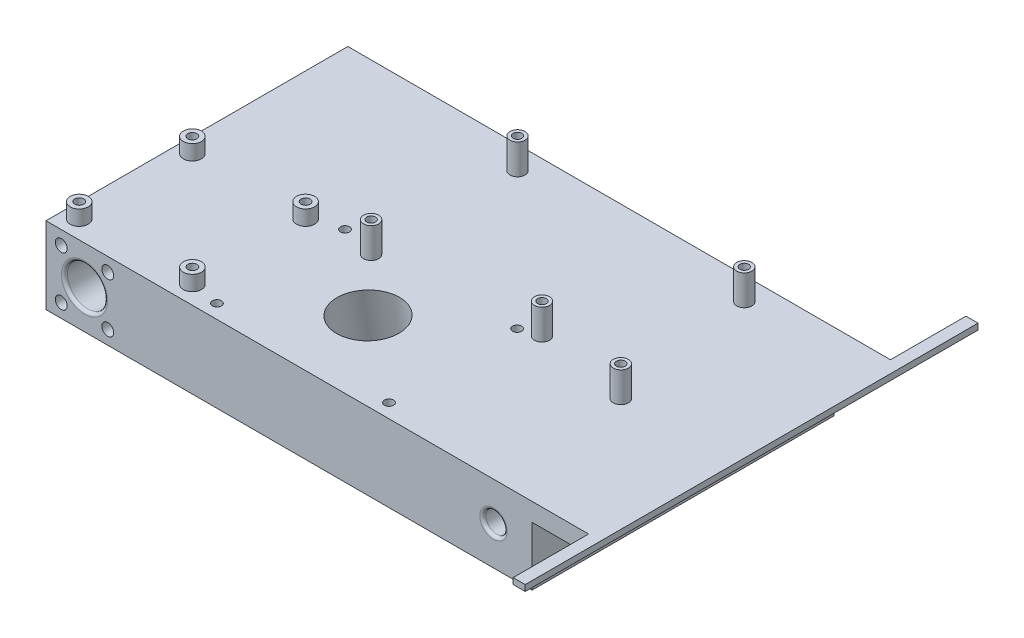
from build123d import *

# Parameters (mm, degrees)
SKETCH1_W                = 161
SKETCH1_H                = 100
BOSS_EXTRUDE1_DEPTH      = 12.75
BOSS_EXTRUDE1_DEPTH_BACK = 12.75
SKETCH2_R                = 6.63
SKETCH2_R_2              = 3.525
SKETCH2_R_3              = 1.975
CUT_EXTRUDE1_DEPTH       = 101
FILLET1_R                = 1
FILLET2_R                = 1
FILLET3_R                = 1
FILLET4_R                = 1
SKETCH3_R                = 2.5
BOSS_EXTRUDE2_DEPTH      = 10
SKETCH4_R                = 1.45
CUT_EXTRUDE2_DEPTH       = 5
SKETCH5_W                = 6
SKETCH5_H                = 13
CUT_EXTRUDE3_DEPTH       = 19.25
SKETCH6_R                = 10.25
CUT_EXTRUDE4_DEPTH       = 43.477415469
SKETCH8_R                = 1.5
CUT_EXTRUDE5_DEPTH       = 36.5
SKETCH11_R               = 3
BOSS_EXTRUDE4_DEPTH      = 5
SKETCH12_R               = 1.5
CUT_EXTRUDE7_DEPTH       = 5
SKETCH13_W               = 18.75
SKETCH13_H               = 6
BOSS_EXTRUDE5_DEPTH      = 100
SKETCH14_W               = 4
SKETCH14_H               = 2
BOSS_EXTRUDE6_DEPTH      = 25
BOSS_EXTRUDE6_DEPTH_BACK = 125


with BuildPart() as part:
    # Sketch1 → Boss-Extrude1 (new body, two sides)
    with BuildSketch(Plane(origin=(0, 0, 0), x_dir=(1, 0, 0), z_dir=(0, 1, 0))) as boss_extrude1_sk:
        Rectangle(SKETCH1_W, SKETCH1_H)
    extrude(amount=BOSS_EXTRUDE1_DEPTH)
    extrude(boss_extrude1_sk.sketch, amount=-BOSS_EXTRUDE1_DEPTH_BACK)

    # Sketch2 → Cut-Extrude1 (cut, through all)
    with BuildSketch(Plane.XY.offset(50)):
        with Locations((-67.75, 0)):
            Circle(SKETCH2_R)
        with Locations((67.75, 0)):
            Circle(SKETCH2_R_2)
        with Locations((-75.45, 8.2)):
            Circle(SKETCH2_R_3)
        with Locations((-75.45, -8.2)):
            Circle(SKETCH2_R_3)
        with Locations((-60.05, -8.2)):
            Circle(SKETCH2_R_3)
        with Locations((-60.05, 8.2)):
            Circle(SKETCH2_R_3)
    extrude(amount=-CUT_EXTRUDE1_DEPTH, mode=Mode.SUBTRACT)

    # Fillet1
    fillet1_edges = [part.edges().sort_by_distance(p)[0] for p in [
        (-74.38, 0, -50),
    ]]
    fillet(fillet1_edges, radius=FILLET1_R)

    # Fillet2
    fillet2_edges = [part.edges().sort_by_distance(p)[0] for p in [
        (-74.38, 0, 50),
    ]]
    fillet(fillet2_edges, radius=FILLET2_R)

    # Fillet3
    fillet3_edges = [part.edges().sort_by_distance(p)[0] for p in [
        (64.225, 0, 50),
    ]]
    fillet(fillet3_edges, radius=FILLET3_R)

    # Fillet4
    fillet4_edges = [part.edges().sort_by_distance(p)[0] for p in [
        (64.225, 0, -50),
    ]]
    fillet(fillet4_edges, radius=FILLET4_R)

    # Sketch3 → Boss-Extrude2 (add)
    with BuildSketch(Plane(origin=(0, 12.75, 0), x_dir=(1, 0, 0), z_dir=(0, 1, 0))):
        with Locations((-16.76, 42.46)):
            Circle(SKETCH3_R)
        with Locations((58.37, 42.46)):
            Circle(SKETCH3_R)
        with Locations((-17, -5.8)):
            Circle(SKETCH3_R)
        with Locations((34.7, -0.9)):
            Circle(SKETCH3_R)
        with Locations((65.72, -5.8)):
            Circle(SKETCH3_R)
    extrude(amount=BOSS_EXTRUDE2_DEPTH)

    # Sketch4 → Cut-Extrude2 (cut)
    with BuildSketch(Plane(origin=(0, 22.75, 0), x_dir=(1, 0, 0), z_dir=(0, 1, 0))):
        with Locations((-16.76, 42.46)):
            Circle(SKETCH4_R)
        with Locations((-17, -5.8)):
            Circle(SKETCH4_R)
        with Locations((34.7, -0.9)):
            Circle(SKETCH4_R)
        with Locations((65.72, -5.8)):
            Circle(SKETCH4_R)
        with Locations((58.37, 42.46)):
            Circle(SKETCH4_R)
    extrude(amount=-CUT_EXTRUDE2_DEPTH, mode=Mode.SUBTRACT)

    # Sketch5 → Cut-Extrude3 (cut)
    with BuildSketch(Plane(origin=(80.5, 0, 0), x_dir=(0, 0, -1), z_dir=(1, 0, 0))):
        with Locations((-30, 0)):
            Rectangle(SKETCH5_W, SKETCH5_H)
        with Locations((-10, 0)):
            Rectangle(SKETCH5_W, SKETCH5_H)
        with Locations((10, 0)):
            Rectangle(SKETCH5_W, SKETCH5_H)
        with Locations((30, 0)):
            Rectangle(SKETCH5_W, SKETCH5_H)
    extrude(amount=-CUT_EXTRUDE3_DEPTH, mode=Mode.SUBTRACT)

    # Sketch6 → Cut-Extrude4 (cut, through all)
    with BuildSketch(Plane(origin=(0, 20.916044041, 3.688062894), x_dir=(1, 0, 0), z_dir=(0, 0.984807753, 0.173648178))):
        with Locations((0, -21.249093385)):
            Circle(SKETCH6_R)
    extrude(amount=-CUT_EXTRUDE4_DEPTH, mode=Mode.SUBTRACT)

    # Sketch8 → Cut-Extrude5 (cut, through all)
    with BuildSketch(Plane.XZ.offset(12.75)):
        with Locations((28.5, 2.93086019)):
            Circle(SKETCH8_R)
        with Locations((28.5, 45.38111272)):
            Circle(SKETCH8_R)
        with Locations((-28.5, 2.93086019)):
            Circle(SKETCH8_R)
        with Locations((-28.5, 45.38111272)):
            Circle(SKETCH8_R)
    extrude(amount=-CUT_EXTRUDE5_DEPTH, mode=Mode.SUBTRACT)

    # Sketch11 → Boss-Extrude4 (add)
    with BuildSketch(Plane(origin=(0, 12.75, 0), x_dir=(1, 0, 0), z_dir=(0, 1, 0))):
        with Locations((-38, -6.5)):
            Circle(SKETCH11_R)
        with Locations((-38, -44)):
            Circle(SKETCH11_R)
        with Locations((-75.5, -6.5)):
            Circle(SKETCH11_R)
        with Locations((-75.5, -44)):
            Circle(SKETCH11_R)
    extrude(amount=BOSS_EXTRUDE4_DEPTH)

    # Sketch12 → Cut-Extrude7 (cut)
    with BuildSketch(Plane(origin=(0, 17.75, 0), x_dir=(1, 0, 0), z_dir=(0, 1, 0))):
        with Locations((-75.5, -44)):
            Circle(SKETCH12_R)
        with Locations((-75.5, -6.5)):
            Circle(SKETCH12_R)
        with Locations((-38, -6.5)):
            Circle(SKETCH12_R)
        with Locations((-38, -44)):
            Circle(SKETCH12_R)
    extrude(amount=-CUT_EXTRUDE7_DEPTH, mode=Mode.SUBTRACT)

    # Sketch13 → Boss-Extrude5 (add)
    with BuildSketch(Plane.XY.offset(50)):
        with Locations((89.875, 9.75)):
            Rectangle(SKETCH13_W, SKETCH13_H)
    extrude(amount=-BOSS_EXTRUDE5_DEPTH)

    # Sketch14 → Boss-Extrude6 (add, two sides)
    with BuildSketch(Plane.XY.offset(50)) as boss_extrude6_sk:
        with Locations((101.25, 11.75)):
            Rectangle(SKETCH14_W, SKETCH14_H)
    extrude(amount=BOSS_EXTRUDE6_DEPTH)
    extrude(boss_extrude6_sk.sketch, amount=-BOSS_EXTRUDE6_DEPTH_BACK)


solid = part.part
